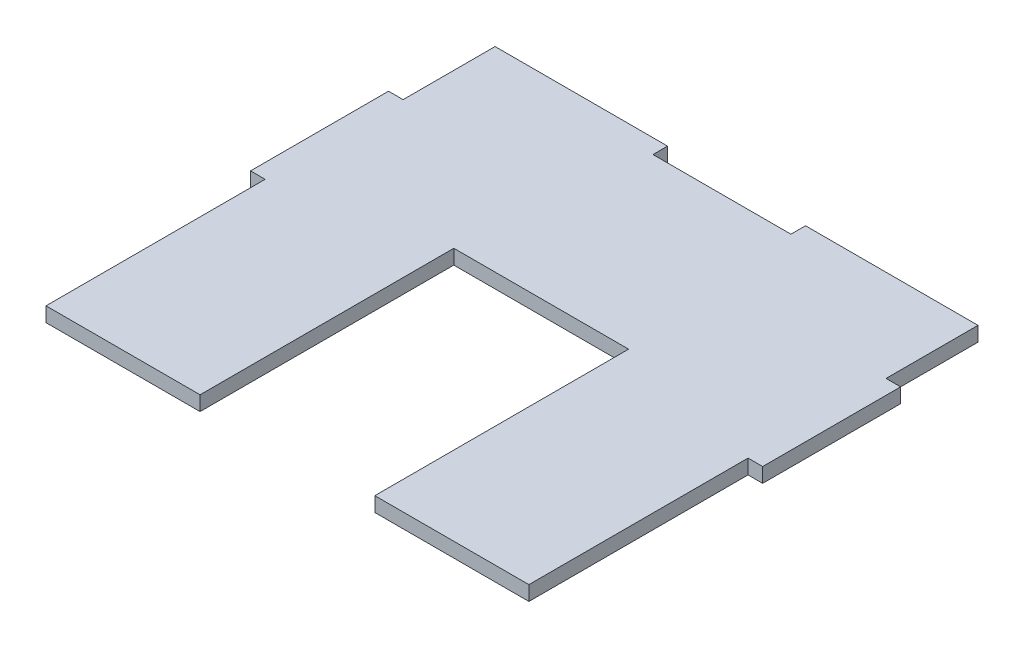
from build123d import *

# Parameters (mm, degrees)
BOSS_EXTRUDE1_DEPTH = 3.175


with BuildPart() as part:
    # Sketch1 → Boss-Extrude1 (new body)
    with BuildSketch(Plane(origin=(0, 0, 0), x_dir=(1, 0, 0), z_dir=(0, 1, 0))):
        Polygon((33.5, 52), (71.5, 52), (71.5, -3.175), (105, -3.175), (105, 44.475), (108.175, 44.475), (108.175, 74.475), (105, 74.475), (105, 94.475), (67.5, 94.475), (67.5, 91.3), (37.5, 91.3), (37.5, 94.475), (0, 94.475), (0, 74.475), (-3.175, 74.475), (-3.175, 44.475), (0, 44.475), (0, -3.175), (33.5, -3.175), align=None)
    extrude(amount=BOSS_EXTRUDE1_DEPTH)


solid = part.part
